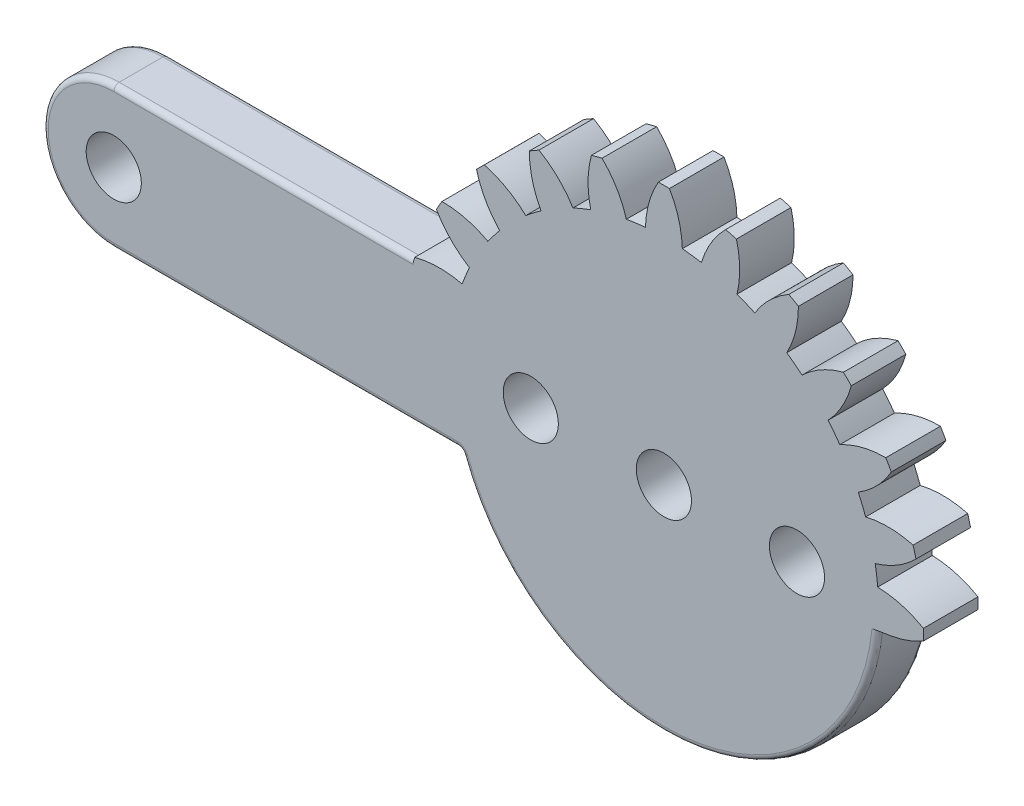
from build123d import *

# Parameters (mm, degrees)
SKETCH_1_R      = 5.05
EXTRUDE_1_DEPTH = 10
FILLET_1_R      = 1


with BuildPart() as part:
    # 草图1 → 凸台-拉伸1 (new body)
    with BuildSketch(Plane.XY):
        with BuildLine():
            Line((39.140934276, -3.548274735), (41.570630213, -3.148020227))
            ThreePointArc((41.570630213, -3.148020227), (44.642381358, -2.351220065), (47.520426727, -1.0142831))
            ThreePointArc((47.520426727, -1.0142831), (47.53125, 0), (47.520426727, 1.0142831))
            ThreePointArc((47.520426727, 1.0142831), (43.486808197, 2.721078851), (39.156174689, 3.375940359))
            ThreePointArc((39.156174689, 3.375940359), (38.965208254, 5.129866986), (38.695718051, 6.873455762))
            ThreePointArc((38.695718051, 6.873455762), (42.709298171, 8.626853835), (46.163723236, 11.319469227))
            ThreePointArc((46.163723236, 11.319469227), (45.911661931, 12.301992738), (45.638691669, 13.27891371))
            ThreePointArc((45.638691669, 13.27891371), (41.300764111, 13.88357451), (36.948202731, 13.395271723))
            ThreePointArc((36.948202731, 13.395271723), (36.309793705, 15.040008999), (35.598212175, 16.654437232))
            ThreePointArc((35.598212175, 16.654437232), (39.021220054, 19.386880688), (41.661038295, 22.881818432))
            ThreePointArc((41.661038295, 22.881818432), (41.163269974, 23.765625), (40.646755194, 24.638608295))
            ThreePointArc((40.646755194, 24.638608295), (36.300141203, 24.09992751), (32.222271816, 22.501737457))
            ThreePointArc((32.222271816, 22.501737457), (31.179926719, 23.925199255), (30.074746968, 25.300446327))
            ThreePointArc((30.074746968, 25.300446327), (32.673910276, 28.825723661), (34.319222442, 32.884809526))
            ThreePointArc((34.319222442, 32.884809526), (33.609669193, 33.609669193), (32.884809526, 34.319222442))
            ThreePointArc((32.884809526, 34.319222442), (28.825723661, 32.673910276), (25.300446327, 30.074746968))
            ThreePointArc((25.300446327, 30.074746968), (23.925199255, 31.179926719), (22.501737457, 32.222271816))
            ThreePointArc((22.501737457, 32.222271816), (24.09992751, 36.300141203), (24.638608295, 40.646755194))
            ThreePointArc((24.638608295, 40.646755194), (23.765625, 41.163269974), (22.881818432, 41.661038295))
            ThreePointArc((22.881818432, 41.661038295), (19.386880688, 39.021220054), (16.654437232, 35.598212175))
            ThreePointArc((16.654437232, 35.598212175), (15.040008999, 36.309793705), (13.395271723, 36.948202731))
            ThreePointArc((13.395271723, 36.948202731), (13.88357451, 41.300764111), (13.27891371, 45.638691669))
            ThreePointArc((13.27891371, 45.638691669), (12.301992738, 45.911661931), (11.319469227, 46.163723236))
            ThreePointArc((11.319469227, 46.163723236), (8.626853835, 42.709298171), (6.873455762, 38.695718051))
            ThreePointArc((6.873455762, 38.695718051), (5.129866986, 38.965208254), (3.375940359, 39.156174689))
            ThreePointArc((3.375940359, 39.156174689), (2.721078851, 43.486808197), (1.0142831, 47.520426727))
            ThreePointArc((1.0142831, 47.520426727), (0, 47.53125), (-1.0142831, 47.520426727))
            ThreePointArc((-1.0142831, 47.520426727), (-2.721078851, 43.486808197), (-3.375940359, 39.156174689))
            ThreePointArc((-3.375940359, 39.156174689), (-5.129866986, 38.965208254), (-6.873455762, 38.695718051))
            ThreePointArc((-6.873455762, 38.695718051), (-8.626853835, 42.709298171), (-11.319469227, 46.163723236))
            ThreePointArc((-11.319469227, 46.163723236), (-12.301992738, 45.911661931), (-13.27891371, 45.638691669))
            ThreePointArc((-13.27891371, 45.638691669), (-13.88357451, 41.300764111), (-13.395271723, 36.948202731))
            ThreePointArc((-13.395271723, 36.948202731), (-15.040008999, 36.309793705), (-16.654437232, 35.598212175))
            ThreePointArc((-16.654437232, 35.598212175), (-19.386880688, 39.021220054), (-22.881818432, 41.661038295))
            ThreePointArc((-22.881818432, 41.661038295), (-23.765625, 41.163269974), (-24.638608295, 40.646755194))
            ThreePointArc((-24.638608295, 40.646755194), (-24.09992751, 36.300141203), (-22.501737457, 32.222271816))
            ThreePointArc((-22.501737457, 32.222271816), (-23.925199255, 31.179926719), (-25.300446327, 30.074746968))
            ThreePointArc((-25.300446327, 30.074746968), (-28.825723661, 32.673910276), (-32.884809526, 34.319222442))
            ThreePointArc((-32.884809526, 34.319222442), (-33.609669193, 33.609669193), (-34.319222442, 32.884809526))
            ThreePointArc((-34.319222442, 32.884809526), (-32.673910276, 28.825723661), (-30.074746968, 25.300446327))
            ThreePointArc((-30.074746968, 25.300446327), (-31.179926719, 23.925199255), (-32.222271816, 22.501737457))
            ThreePointArc((-32.222271816, 22.501737457), (-36.300141203, 24.09992751), (-40.646755194, 24.638608295))
            ThreePointArc((-40.646755194, 24.638608295), (-41.163269974, 23.765625), (-41.661038295, 22.881818432))
            ThreePointArc((-41.661038295, 22.881818432), (-39.021220054, 19.386880688), (-35.598212175, 16.654437232))
            ThreePointArc((-35.598212175, 16.654437232), (-36.309793705, 15.040008999), (-36.948202731, 13.395271723))
            ThreePointArc((-36.948202731, 13.395271723), (-41.300764111, 13.88357451), (-45.638691669, 13.27891371))
            ThreePointArc((-45.638691669, 13.27891371), (-45.679019155, 13.13951809), (-45.718920881, 13))
            Line((-45.718920881, 13), (-100.75, 13))
            ThreePointArc((-100.75, 13), (-113.75, 0), (-100.75, -13))
            Line((-100.75, -13), (-37.089122254, -13))
            ThreePointArc((-37.089122254, -13), (4.835934322, -39.002778475), (39.140934276, -3.548274735))
        make_face()
        with Locations((24.375, 0)):
            Circle(SKETCH_1_R, mode=Mode.SUBTRACT)
        Circle(SKETCH_1_R, mode=Mode.SUBTRACT)
        with Locations((-24.375, 0)):
            Circle(SKETCH_1_R, mode=Mode.SUBTRACT)
        with Locations((-100.75, 0)):
            Circle(SKETCH_1_R, mode=Mode.SUBTRACT)
    extrude(amount=EXTRUDE_1_DEPTH)

    # 圆角1
    fillet_1_edges = [part.edges().sort_by_distance(p)[0] for p in [
        (-73.234460441, 13, 10),
        (-113.75, 0, 10),
        (-68.919561127, -13, 10),
        (-68.919561127, -13, 0),
        (-113.75, 0, 0),
        (-73.234460441, 13, 0),
        (4.835934322, -39.002778475, 10),
        (4.835934322, -39.002778475, 0),
        (-37.089122254, -13, 5),
    ]]
    fillet(fillet_1_edges, radius=FILLET_1_R)


solid = part.part
